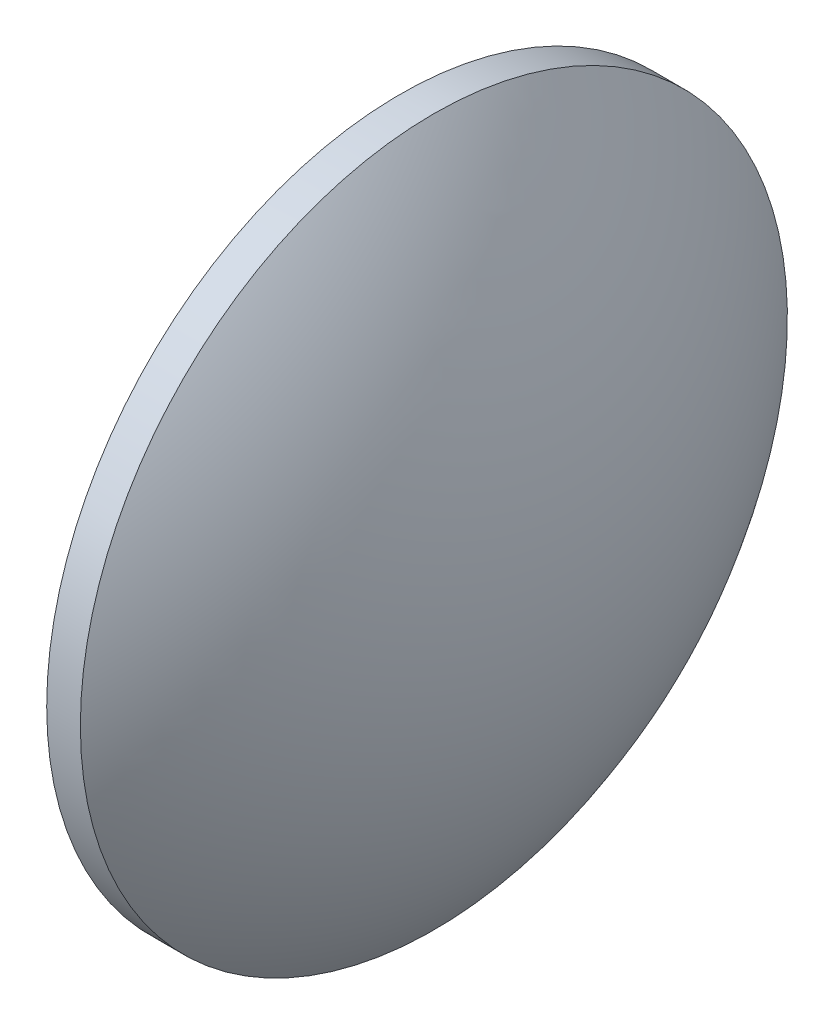
from build123d import *


with BuildPart() as part:
    # 草图1 → 旋转1 (revolve)
    with BuildSketch(Plane.XY):
        with BuildLine():
            Line((385.701133387, 17.731663399), (385.701133387, 49.231663399))
            Line((385.701133387, 49.231663399), (388.701133387, 49.231663399))
            ThreePointArc((388.701133387, 49.231663399), (396.667729163, 34.368733453), (399.421133387, 17.731663399))
            Line((399.421133387, 17.731663399), (385.701133387, 17.731663399))
        make_face()
    revolve(axis=Axis((366.662178325, 17.731663399, 0), (1, 0, 0)))


solid = part.part
